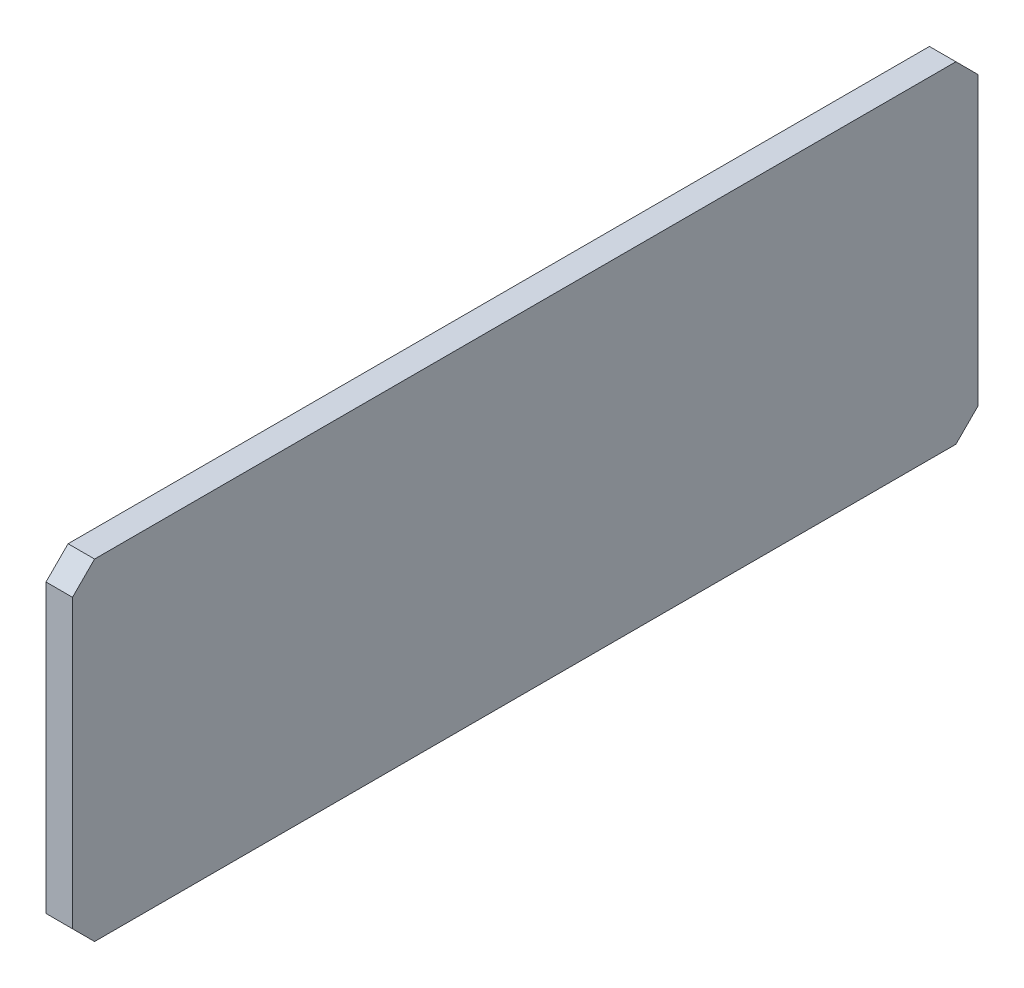
from build123d import *

# Parameters (mm, degrees)
ESQUISSE1_W        = 12
ESQUISSE1_H        = 150
BOSS_EXTRU_1_DEPTH = 410
CHANFREIN1_SIZE    = 10


with BuildPart() as part:
    # Esquisse1 → Boss.-Extru.1 (new body)
    with BuildSketch(Plane.XY):
        Rectangle(ESQUISSE1_W, ESQUISSE1_H)
    extrude(amount=BOSS_EXTRU_1_DEPTH)

    # Chanfrein1
    chanfrein1_edges = [part.edges().sort_by_distance(p)[0] for p in [
        (0, -75, 410),
        (0, -75, 0),
        (0, 75, 0),
        (0, 75, 410),
    ]]
    chamfer(chanfrein1_edges, length=CHANFREIN1_SIZE)


solid = part.part
